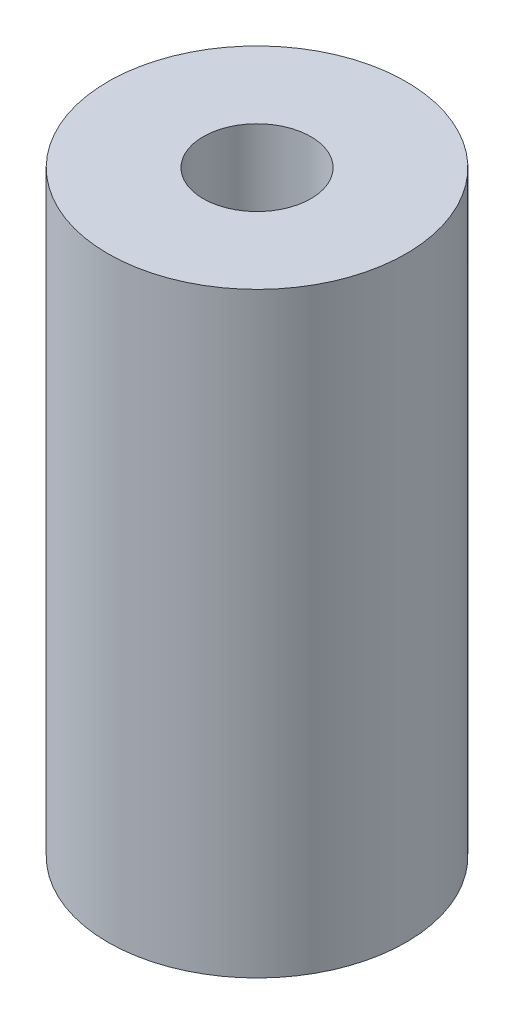
from build123d import *

# Parameters (mm, degrees)
SKETCH1_R           = 2.38125
SKETCH1_R_2         = 0.859478874
BOSS_EXTRUDE1_DEPTH = 9.525


with BuildPart() as part:
    # Sketch1 → Boss-Extrude1 (new body)
    with BuildSketch(Plane(origin=(0, 0, 0), x_dir=(1, 0, 0), z_dir=(0, 1, 0))):
        Circle(SKETCH1_R)
        Circle(SKETCH1_R_2, mode=Mode.SUBTRACT)
    extrude(amount=BOSS_EXTRUDE1_DEPTH)


solid = part.part
